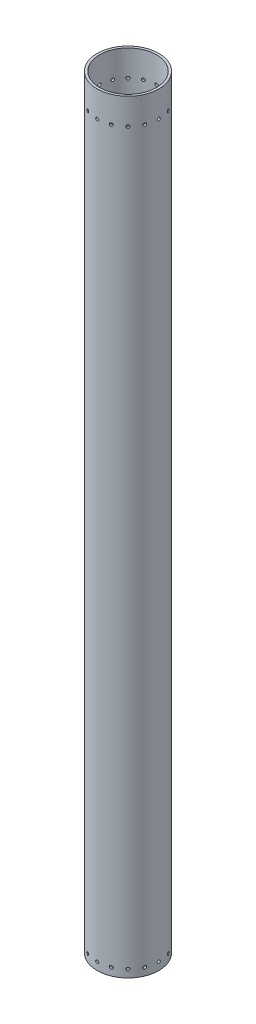
from build123d import *

# Parameters (mm, degrees)
SKETCH1_R                = 63.5
SKETCH1_R_2              = 58.7375
CASINGBODY_DEPTH         = 1574.8
NOZZLEHOLES_D            = 6.35
NOZZLEHOLEPATTERN_COUNT  = 16
CLOSUREHOLES_D           = 6.35
CLOSUREHOLEPATTERN_COUNT = 16


with BuildPart() as part:
    # Sketch1 → CasingBody (new body)
    with BuildSketch(Plane(origin=(0, 0, 0), x_dir=(1, 0, 0), z_dir=(0, 1, 0))):
        Circle(SKETCH1_R)
        Circle(SKETCH1_R_2, mode=Mode.SUBTRACT)
    extrude(amount=CASINGBODY_DEPTH)

    # NozzleHoles (through all)
    with Locations(Plane.XY.offset(63.5)):
        with Locations((0, 15.875)):
            nozzleholes = Hole(NOZZLEHOLES_D / 2)

    # NozzleHolePattern: NozzleHoles ×16 about axis
    nozzleholepattern_axis = Axis((0, 0, 0), (0, 1, 0))
    for i in range(1, NOZZLEHOLEPATTERN_COUNT):
        add(nozzleholes.rotate(nozzleholepattern_axis, i * 360 / NOZZLEHOLEPATTERN_COUNT), mode=Mode.SUBTRACT)

    # ClosureHoles (through all)
    with Locations(Plane.XY.offset(63.5)):
        with Locations((0, 1520.825)):
            closureholes = Hole(CLOSUREHOLES_D / 2)

    # ClosureHolePattern: ClosureHoles ×16 about axis
    closureholepattern_axis = Axis((0, 0, 0), (0, 1, 0))
    for i in range(1, CLOSUREHOLEPATTERN_COUNT):
        add(closureholes.rotate(closureholepattern_axis, i * 360 / CLOSUREHOLEPATTERN_COUNT), mode=Mode.SUBTRACT)


solid = part.part
